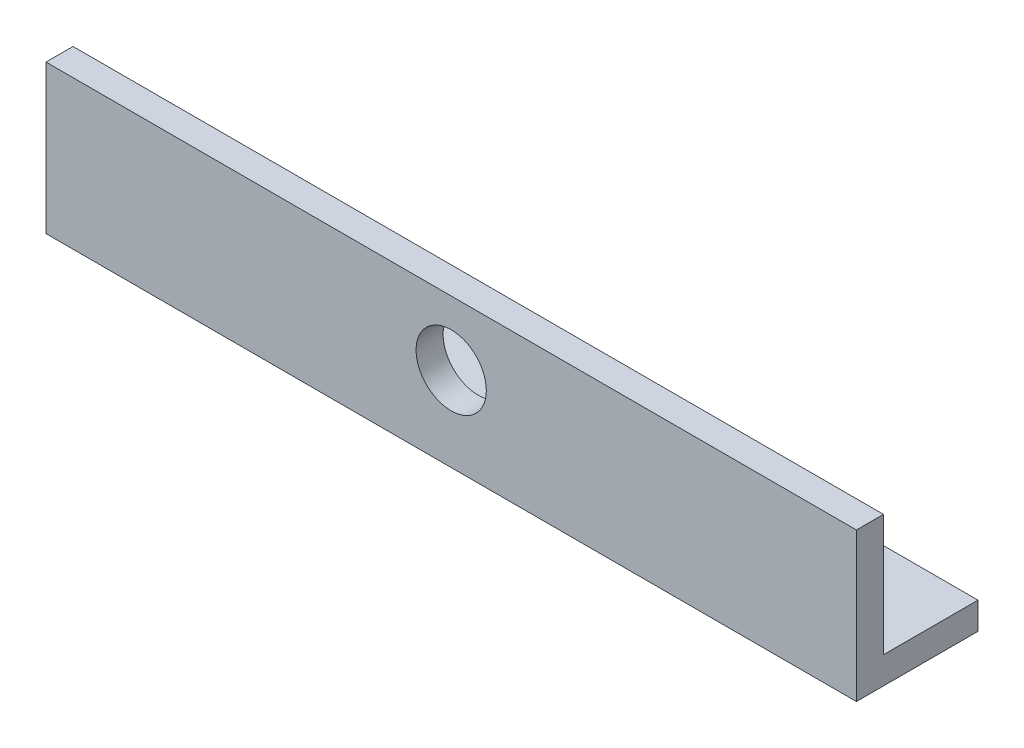
from build123d import *

# Parameters (mm, degrees)
EXTRUDE_THIN1_DEPTH = 150
SKETCH2_R           = 13
CUT_EXTRUDE1_DEPTH  = 46


with BuildPart() as part:
    # Sketch1 → Extrude-Thin1 (new body, symmetric)
    with BuildSketch(Plane(origin=(0, 0, 0), x_dir=(0, 0, -1), z_dir=(1, 0, 0))):
        Polygon((-5, 23.80952381), (-5, -31.19047619), (40, -31.19047619), (40, -21.19047619), (5, -21.19047619), (5, 23.80952381), align=None)
    extrude(amount=EXTRUDE_THIN1_DEPTH, both=True)

    # Sketch2 → Cut-Extrude1 (cut, through all)
    with BuildSketch(Plane.XY.offset(5)):
        Circle(SKETCH2_R)
    extrude(amount=-CUT_EXTRUDE1_DEPTH, mode=Mode.SUBTRACT)


solid = part.part
